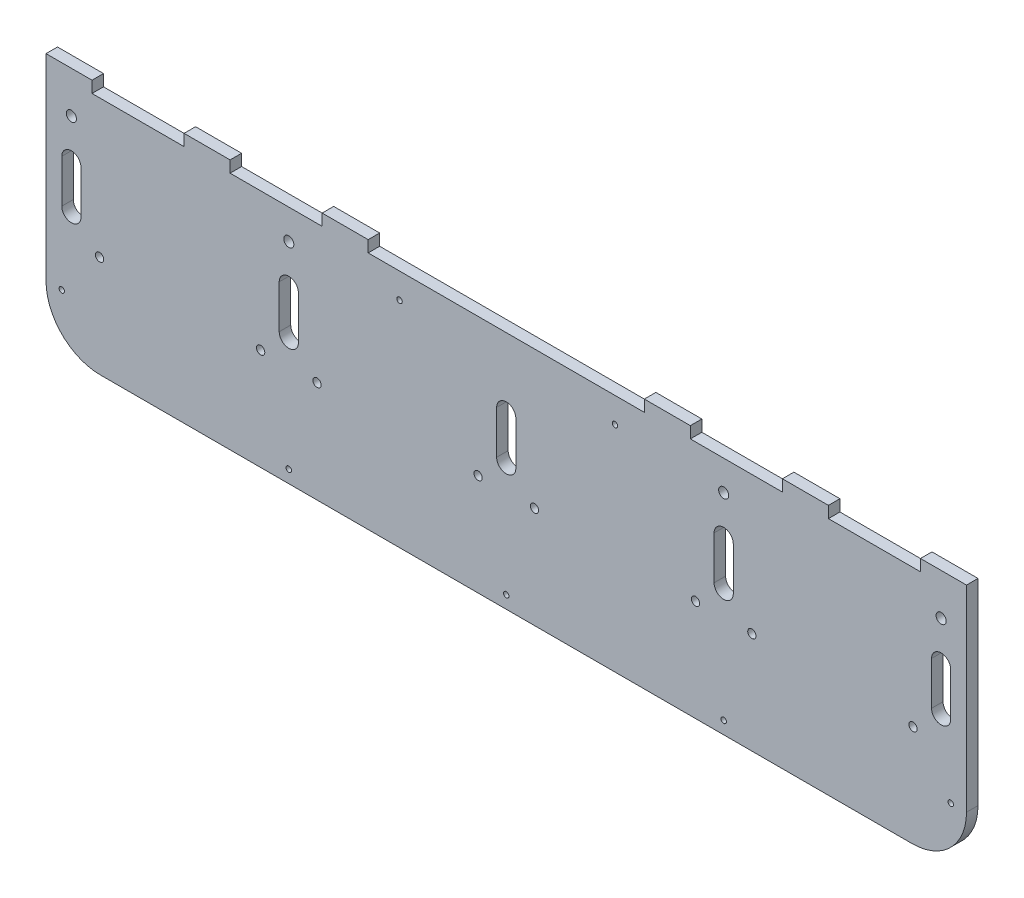
from build123d import *

# Parameters (mm, degrees)
SKETCH1_R           = 1.5
SKETCH1_R_2         = 2.286
SKETCH1_R_3         = 2.794
BOSS_EXTRUDE1_DEPTH = 6.35


with BuildPart() as part:
    # Sketch1 → Boss-Extrude1 (new body)
    with BuildSketch(Plane.XY):
        with BuildLine():
            Line((-491.330243723, 4.906575793), (-491.330243723, -1.443424207))
            Line((-491.330243723, -1.443424207), (-491.330243723, -103.680930126))
            ThreePointArc((-491.330243723, -103.680930126), (-482.543447159, -124.894133561), (-461.330243723, -133.680930126))
            Line((-461.330243723, -133.680930126), (-13.330243723, -133.680930126))
            ThreePointArc((-13.330243723, -133.680930126), (7.882959712, -124.894133561), (16.669756277, -103.680930126))
            Line((16.669756277, -103.680930126), (16.669756277, -1.443424207))
            Line((16.669756277, -1.443424207), (16.669756277, 4.906575793))
            Line((16.669756277, 4.906575793), (-8.730243723, 4.906575793))
            Line((-8.730243723, 4.906575793), (-8.730243723, -1.443424207))
            Line((-8.730243723, -1.443424207), (-59.530243723, -1.443424207))
            Line((-59.530243723, -1.443424207), (-59.530243723, 4.906575793))
            Line((-59.530243723, 4.906575793), (-84.930243723, 4.906575793))
            Line((-84.930243723, 4.906575793), (-84.930243723, -1.443424207))
            Line((-84.930243723, -1.443424207), (-135.730243723, -1.443424207))
            Line((-135.730243723, -1.443424207), (-135.730243723, 4.906575793))
            Line((-135.730243723, 4.906575793), (-161.130243723, 4.906575793))
            Line((-161.130243723, 4.906575793), (-161.130243723, -1.443424207))
            Line((-161.130243723, -1.443424207), (-313.530243723, -1.443424207))
            Line((-313.530243723, -1.443424207), (-313.530243723, 4.906575793))
            Line((-313.530243723, 4.906575793), (-338.930243723, 4.906575793))
            Line((-338.930243723, 4.906575793), (-338.930243723, -1.443424207))
            Line((-338.930243723, -1.443424207), (-389.730243723, -1.443424207))
            Line((-389.730243723, -1.443424207), (-389.730243723, 4.906575793))
            Line((-389.730243723, 4.906575793), (-415.130243723, 4.906575793))
            Line((-415.130243723, 4.906575793), (-415.130243723, -1.443424207))
            Line((-415.130243723, -1.443424207), (-465.930243723, -1.443424207))
            Line((-465.930243723, -1.443424207), (-465.930243723, 4.906575793))
            Line((-465.930243723, 4.906575793), (-491.330243723, 4.906575793))
        make_face()
        with Locations((-482.62608839, -103.680930126)):
            Circle(SKETCH1_R, mode=Mode.SUBTRACT)
        with Locations((-357.330243723, -126.721486066)):
            Circle(SKETCH1_R, mode=Mode.SUBTRACT)
        with Locations((-461.780243723, -77.562177166)):
            Circle(SKETCH1_R_2, mode=Mode.SUBTRACT)
        with Locations((-372.880243723, -77.562177166)):
            Circle(SKETCH1_R_2, mode=Mode.SUBTRACT)
        with Locations((-341.780243723, -77.562177166)):
            Circle(SKETCH1_R_2, mode=Mode.SUBTRACT)
        with Locations((-252.880243723, -77.562177166)):
            Circle(SKETCH1_R_2, mode=Mode.SUBTRACT)
        with Locations((-237.330243723, -126.721486066)):
            Circle(SKETCH1_R, mode=Mode.SUBTRACT)
        with Locations((-117.330243723, -126.721486066)):
            Circle(SKETCH1_R, mode=Mode.SUBTRACT)
        with Locations((7.965600943, -103.680930126)):
            Circle(SKETCH1_R, mode=Mode.SUBTRACT)
        with Locations((-221.780243723, -77.562177166)):
            Circle(SKETCH1_R_2, mode=Mode.SUBTRACT)
        with Locations((-132.880243723, -77.562177166)):
            Circle(SKETCH1_R_2, mode=Mode.SUBTRACT)
        with Locations((-101.780243723, -77.562177166)):
            Circle(SKETCH1_R_2, mode=Mode.SUBTRACT)
        with Locations((-12.880243723, -77.562177166)):
            Circle(SKETCH1_R_2, mode=Mode.SUBTRACT)
        with BuildLine():
            ThreePointArc((-482.62608839, -39.813208936), (-477.330243723, -34.51736427), (-472.034399057, -39.813208936))
            Line((-472.034399057, -39.813208936), (-472.034399057, -63.648583111))
            ThreePointArc((-472.034399057, -63.648583111), (-477.330243723, -68.944427778), (-482.62608839, -63.648583111))
            Line((-482.62608839, -63.648583111), (-482.62608839, -39.813208936))
        make_face(mode=Mode.SUBTRACT)
        with BuildLine():
            ThreePointArc((-362.62608839, -39.813208936), (-357.330243723, -34.51736427), (-352.034399057, -39.813208936))
            Line((-352.034399057, -39.813208936), (-352.034399057, -63.648583111))
            ThreePointArc((-352.034399057, -63.648583111), (-357.330243723, -68.944427778), (-362.62608839, -63.648583111))
            Line((-362.62608839, -63.648583111), (-362.62608839, -39.813208936))
        make_face(mode=Mode.SUBTRACT)
        with Locations((-477.330243723, -17.953424207)):
            Circle(SKETCH1_R_3, mode=Mode.SUBTRACT)
        with Locations((-357.330243723, -17.953424207)):
            Circle(SKETCH1_R_3, mode=Mode.SUBTRACT)
        with Locations((-296.221681692, -15.413424207)):
            Circle(SKETCH1_R, mode=Mode.SUBTRACT)
        with BuildLine():
            ThreePointArc((-242.62608839, -39.813208936), (-237.330243723, -34.51736427), (-232.034399057, -39.813208936))
            Line((-232.034399057, -39.813208936), (-232.034399057, -63.648583111))
            ThreePointArc((-232.034399057, -63.648583111), (-237.330243723, -68.944427778), (-242.62608839, -63.648583111))
            Line((-242.62608839, -63.648583111), (-242.62608839, -39.813208936))
        make_face(mode=Mode.SUBTRACT)
        with BuildLine():
            ThreePointArc((-122.62608839, -39.813208936), (-117.330243723, -34.51736427), (-112.034399057, -39.813208936))
            Line((-112.034399057, -39.813208936), (-112.034399057, -63.648583111))
            ThreePointArc((-112.034399057, -63.648583111), (-117.330243723, -68.944427778), (-122.62608839, -63.648583111))
            Line((-122.62608839, -63.648583111), (-122.62608839, -39.813208936))
        make_face(mode=Mode.SUBTRACT)
        with BuildLine():
            ThreePointArc((-2.62608839, -39.813208936), (2.669756277, -34.51736427), (7.965600943, -39.813208936))
            Line((7.965600943, -39.813208936), (7.965600943, -63.648583111))
            ThreePointArc((7.965600943, -63.648583111), (2.669756277, -68.944427778), (-2.62608839, -63.648583111))
            Line((-2.62608839, -63.648583111), (-2.62608839, -39.813208936))
        make_face(mode=Mode.SUBTRACT)
        with Locations((-177.33024378, -15.413424207)):
            Circle(SKETCH1_R, mode=Mode.SUBTRACT)
        with Locations((-117.330243723, -17.953424207)):
            Circle(SKETCH1_R_3, mode=Mode.SUBTRACT)
        with Locations((2.669756277, -17.953424207)):
            Circle(SKETCH1_R_3, mode=Mode.SUBTRACT)
    extrude(amount=BOSS_EXTRUDE1_DEPTH)


solid = part.part
